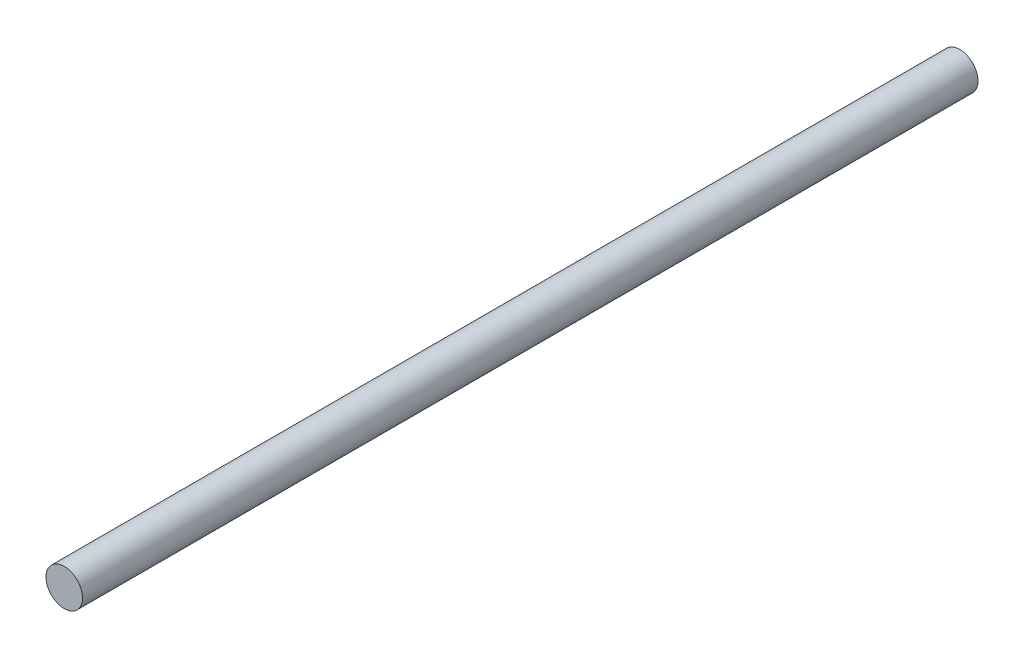
from build123d import *

# Parameters (mm, degrees)
SKETCH_1_R      = 4
EXTRUDE_1_DEPTH = 196


with BuildPart() as part:
    # 草图1 → 凸台-拉伸1 (new body)
    with BuildSketch(Plane.XY):
        Circle(SKETCH_1_R)
    extrude(amount=EXTRUDE_1_DEPTH)


solid = part.part
